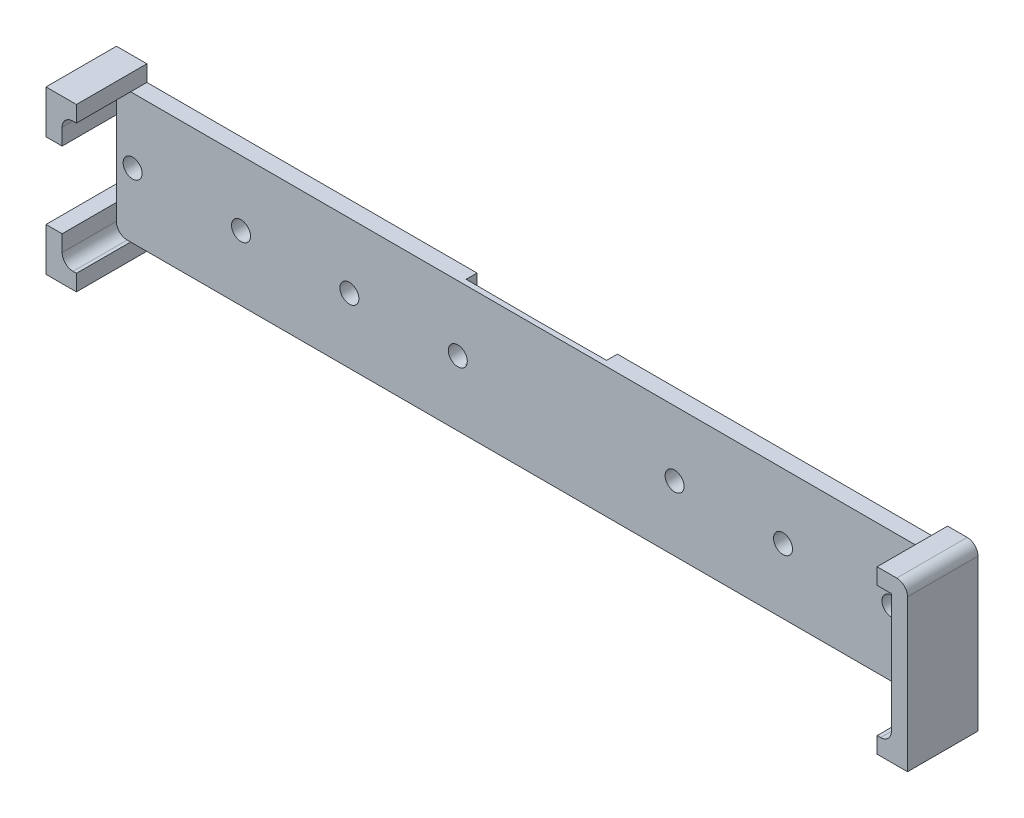
from build123d import *

# Parameters (mm, degrees)
SKETCH1_W                = 153
SKETCH1_H                = 24
BOSS_EXTRUDE1_DEPTH      = 3
BOSS_EXTRUDE2_DEPTH      = 10
BOSS_EXTRUDE2_DEPTH_BACK = 3
CUT_EXTRUDE1_DEPTH       = 3.977609852
CUT_EXTRUDE1_DEPTH_BACK  = 27.977609852
CUT_EXTRUDE2_START       = -4
SKETCH5_R                = 1.75
CUT_EXTRUDE2_DEPTH       = 15
FILLET1_R                = 2
LPATTERN1_COUNT          = 8
LPATTERN1_PITCH          = 20


with BuildPart() as part:
    # Sketch1 → Boss-Extrude1 (new body)
    with BuildSketch(Plane.XY):
        Rectangle(SKETCH1_W, SKETCH1_H)
    extrude(amount=BOSS_EXTRUDE1_DEPTH)

    # Sketch3 → Boss-Extrude2 (add, two sides)
    with BuildSketch(Plane.XY.offset(3)) as boss_extrude2_sk:
        Polygon((-79.477609852, -9.365840911), (-79.477609852, -12.365840911), (-79.477609852, -14.977609852), (-76.865840911, -14.977609852), (-73.865840911, -14.977609852), (-73.865840911, -12), (-76.5, -12), (-76.5, -9.365840911), (-76.5, -7), (-79.477609852, -7), align=None)
        Polygon((-73.865840911, 14.977609852), (-73.865840911, 12), (-76.5, 12), (-76.5, 9.365840911), (-76.5, 7), (-79.477609852, 7), (-79.477609852, 9.365840911), (-79.477609852, 12.365840911), (-79.477609852, 14.977609852), (-76.865840911, 14.977609852), align=None)
        Polygon((79.477609852, 9.365840911), (79.477609852, -9.365840911), (79.477609852, -12.365840911), (79.477609852, -14.977609852), (76.865840911, -14.977609852), (73.865840911, -14.977609852), (73.865840911, -12), (76.5, -12), (76.5, -9.365840911), (76.5, 9.365840911), (76.5, 12), (73.865840911, 12), (73.865840911, 14.977609852), (76.865840911, 14.977609852), (79.477609852, 14.977609852), (79.477609852, 12.365840911), align=None)
    extrude(amount=BOSS_EXTRUDE2_DEPTH)
    extrude(boss_extrude2_sk.sketch, amount=-BOSS_EXTRUDE2_DEPTH_BACK)

    # Sketch4 → Cut-Extrude1 (cut, two sides)
    with BuildSketch(Plane.XZ.offset(12)) as cut_extrude1_sk:
        Polygon((-12.954, 2), (-12.954, 0), (12.954, 0), (12.954, 2), (0, 2.06825053), align=None)
    extrude(amount=CUT_EXTRUDE1_DEPTH, mode=Mode.SUBTRACT)
    extrude(cut_extrude1_sk.sketch, amount=-CUT_EXTRUDE1_DEPTH_BACK, mode=Mode.SUBTRACT)

    # Sketch5 → Cut-Extrude2 (cut)
    with BuildSketch(Plane.XY.offset(3).offset(CUT_EXTRUDE2_START)):
        with Locations((-73.5, 0)):
            Circle(SKETCH5_R)
    cut_extrude2 = extrude(amount=CUT_EXTRUDE2_DEPTH, mode=Mode.SUBTRACT)

    # Fillet1
    fillet1_edges = [part.edges().sort_by_distance(p)[0] for p in [
        (-76.5, 12, 8),
        (-76.5, -12, 8),
        (76.5, -12, 8),
        (79.477609852, 14.977609852, 6.5),
    ]]
    fillet(fillet1_edges, radius=FILLET1_R)

    # LPattern1: Cut-Extrude2 ×8, 1 skipped
    with Locations(*[(i * LPATTERN1_PITCH, 0, 0) for i in range(1, LPATTERN1_COUNT) if i not in (4,)]):
        add(cut_extrude2, mode=Mode.SUBTRACT)


solid = part.part
